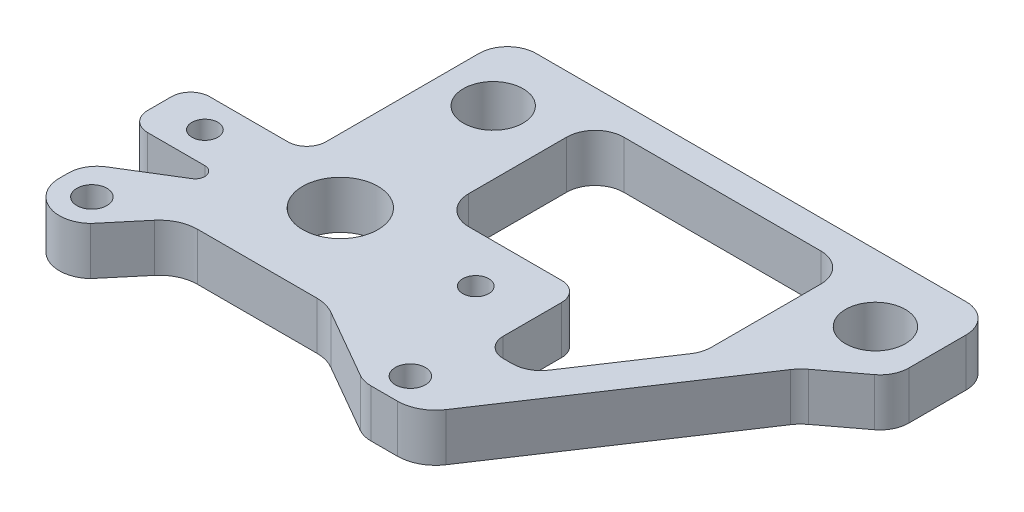
from build123d import *

# Parameters (mm, degrees)
SKETCH4_R           = 2
SKETCH4_R_2         = 1.7272
SKETCH4_R_3         = 5
SKETCH4_R_4         = 3.96875
BOSS_EXTRUDE2_DEPTH = 6.35
FILLET1_R           = 5.08
FILLET7_R           = 3.81
FILLET9_R           = 5.08
FILLET10_R          = 1.27
FILLET11_R          = 3.81
FILLET12_R          = 2.54
FILLET13_R          = 3.81


with BuildPart() as part:
    # Sketch4 → Boss-Extrude2 (new body)
    with BuildSketch(Plane(origin=(0, 0, 0), x_dir=(1, 0, 0), z_dir=(0, 1, 0))):
        with BuildLine():
            Line((22.483900583, -18.4375), (28.735494078, -18.4375))
            Line((28.735494078, -18.4375), (48.985566477, 12.027918285))
            Line((48.985566477, 12.027918285), (54.680415238, 16.319294633))
            ThreePointArc((54.680415238, 16.319294633), (55.797199918, 17.662082259), (56.1975, 19.362095927))
            Line((56.1975, 19.362095927), (56.1975, 26.9875))
            ThreePointArc((56.1975, 26.9875), (55.081576836, 29.681576836), (52.3875, 30.7975))
            Line((52.3875, 30.7975), (-4.7625, 30.7975))
            ThreePointArc((-4.7625, 30.7975), (-7.456576836, 29.681576836), (-8.5725, 26.9875))
            Line((-8.5725, 26.9875), (-8.5725, 12.607500122))
            Line((-8.5725, 12.607500122), (-8.5725, 4.1275))
            Line((-8.5725, 4.1275), (-24.03032317, 4.1275))
            Line((-24.03032317, 4.1275), (-24.03032317, -4.1275))
            Line((-24.03032317, -4.1275), (-9.399713355, -4.1275))
            Line((-9.399713355, -4.1275), (-22.098, -11.933490986))
            Line((-22.098, -11.933490986), (-22.098, -15.24))
            ThreePointArc((-22.098, -15.24), (-19.494143335, -19.203185162), (-14.822948297, -18.386580561))
            Line((-14.822948297, -18.386580561), (-9.399713355, -11.933490986))
            Line((-9.399713355, -11.933490986), (10.16293305, -11.933490986))
            Line((10.16293305, -11.933490986), (20.583679925, -17.929811531))
            ThreePointArc((20.583679925, -17.929811531), (21.500464498, -18.308390309), (22.483900583, -18.4375))
        make_face()
        with Locations((-17.78, -15.24)):
            Circle(SKETCH4_R, mode=Mode.SUBTRACT)
        with Locations((-18.000000004, 0)):
            Circle(SKETCH4_R_2, mode=Mode.SUBTRACT)
        Circle(SKETCH4_R_3, mode=Mode.SUBTRACT)
        with Locations((24.012521227, -14.703599027)):
            Circle(SKETCH4_R, mode=Mode.SUBTRACT)
        with Locations((18.000000004, 0)):
            Circle(SKETCH4_R_2, mode=Mode.SUBTRACT)
        with Locations((-1.5875, 21.9075)):
            Circle(SKETCH4_R_4, mode=Mode.SUBTRACT)
        Polygon((6.882386285, 6.3725), (6.882386285, 26.9875), (40.692955064, 26.9875), (40.692955064, 7.472580753), (31.404651622, -6.501297657), (25.585775375, -6.501297657), (25.585775375, 6.3725), align=None, mode=Mode.SUBTRACT)
        with Locations((49.2125, 21.9075)):
            Circle(SKETCH4_R_4, mode=Mode.SUBTRACT)
    extrude(amount=-BOSS_EXTRUDE2_DEPTH)

    # Fillet1
    fillet1_edges = [part.edges().sort_by_distance(p)[0] for p in [
        (48.985566477, -3.175, -12.027918285),
        (28.735494078, -3.175, 18.4375),
    ]]
    fillet(fillet1_edges, radius=FILLET1_R)

    # Fillet7
    fillet7_edges = [part.edges().sort_by_distance(p)[0] for p in [
        (40.692955064, -3.175, -7.472580753),
        (40.692955064, -3.175, -26.9875),
        (6.882386285, -3.175, -26.9875),
        (6.882386285, -3.175, -6.3725),
    ]]
    fillet(fillet7_edges, radius=FILLET7_R)

    # Fillet9
    fillet9_edges = [part.edges().sort_by_distance(p)[0] for p in [
        (10.16293305, -3.175, 11.933490986),
        (-9.399713355, -3.175, 11.933490986),
    ]]
    fillet(fillet9_edges, radius=FILLET9_R)

    # Fillet10
    fillet10_edges = [part.edges().sort_by_distance(p)[0] for p in [
        (-9.399713355, -3.175, 4.1275),
    ]]
    fillet(fillet10_edges, radius=FILLET10_R)

    # Fillet11
    fillet11_edges = [part.edges().sort_by_distance(p)[0] for p in [
        (-22.098, -3.175, 11.933490986),
    ]]
    fillet(fillet11_edges, radius=FILLET11_R)

    # Fillet12
    fillet12_edges = [part.edges().sort_by_distance(p)[0] for p in [
        (25.585775375, -3.175, -6.3725),
        (25.585775375, -3.175, 6.501297657),
        (-24.03032317, -3.175, 4.1275),
        (-24.03032317, -3.175, -4.1275),
        (-8.5725, -3.175, -4.1275),
    ]]
    fillet(fillet12_edges, radius=FILLET12_R)

    # Fillet13
    fillet13_edges = [part.edges().sort_by_distance(p)[0] for p in [
        (31.404651622, -3.175, 6.501297657),
    ]]
    fillet(fillet13_edges, radius=FILLET13_R)


solid = part.part
